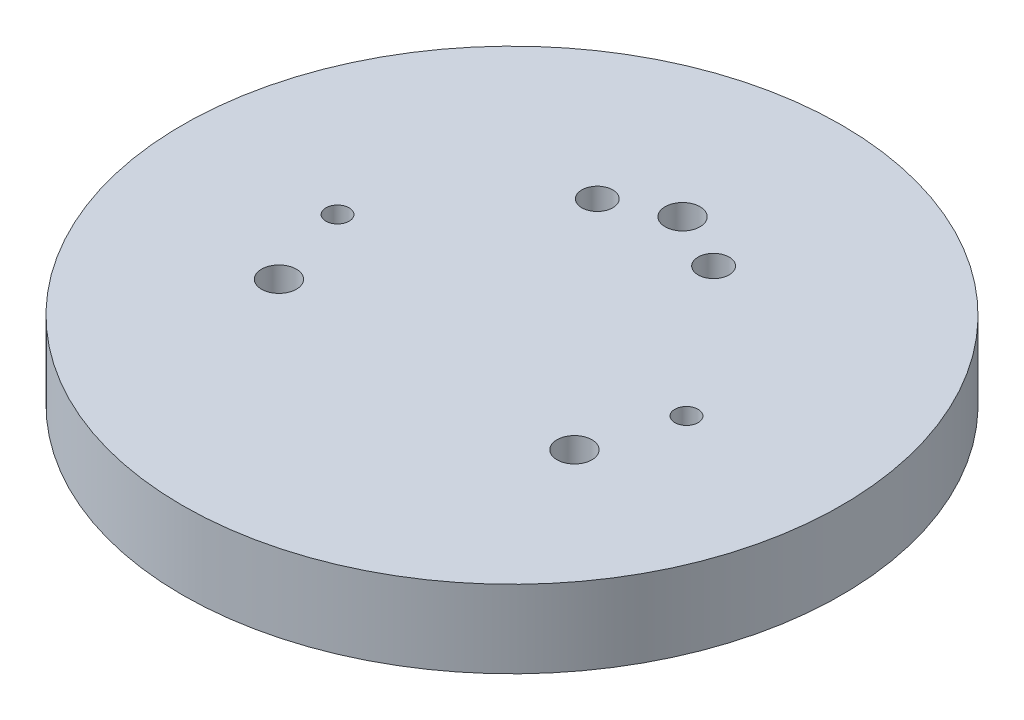
from build123d import *

# Parameters (mm, degrees)
SKETCH1_R           = 42.5
BOSS_EXTRUDE1_DEPTH = 10
SKETCH2_R           = 1.5
CUT_EXTRUDE1_DEPTH  = 5
SKETCH3_R           = 2.25
CUT_EXTRUDE2_DEPTH  = 11
SKETCH4_R           = 5
CUT_EXTRUDE3_DEPTH  = 4.4
SKETCH5_R           = 2
CUT_EXTRUDE4_DEPTH  = 11


with BuildPart() as part:
    # Sketch1 → Boss-Extrude1 (new body)
    with BuildSketch(Plane(origin=(0, 0, 0), x_dir=(1, 0, 0), z_dir=(0, 1, 0))):
        Circle(SKETCH1_R)
    extrude(amount=BOSS_EXTRUDE1_DEPTH)

    # Sketch2 → Cut-Extrude1 (cut)
    with BuildSketch(Plane(origin=(0, 10, 0), x_dir=(1, 0, 0), z_dir=(0, 1, 0))):
        with Locations((-22.5, 0)):
            Circle(SKETCH2_R)
        with Locations((22.5, 0)):
            Circle(SKETCH2_R)
    extrude(amount=-CUT_EXTRUDE1_DEPTH, mode=Mode.SUBTRACT)

    # Sketch3 → Cut-Extrude2 (cut, through all)
    with BuildSketch(Plane(origin=(0, 10, 0), x_dir=(1, 0, 0), z_dir=(0, 1, 0))):
        with Locations((0, 22)):
            Circle(SKETCH3_R)
        with Locations((19.052558883, -11)):
            Circle(SKETCH3_R)
        with Locations((-19.052558883, -11)):
            Circle(SKETCH3_R)
    extrude(amount=-CUT_EXTRUDE2_DEPTH, mode=Mode.SUBTRACT)

    # Sketch4 → Cut-Extrude3 (cut)
    with BuildSketch(Plane.XZ):
        with Locations((0, -22)):
            Circle(SKETCH4_R)
        with Locations((19.052558883, 11)):
            Circle(SKETCH4_R)
        with Locations((-19.052558883, 11)):
            Circle(SKETCH4_R)
    extrude(amount=-CUT_EXTRUDE3_DEPTH, mode=Mode.SUBTRACT)

    # Sketch5 → Cut-Extrude4 (cut, through all)
    with BuildSketch(Plane(origin=(0, 10, 0), x_dir=(1, 0, 0), z_dir=(0, 1, 0))):
        with Locations((-7.5, 18.5)):
            Circle(SKETCH5_R)
        with Locations((7.5, 18.5)):
            Circle(SKETCH5_R)
    extrude(amount=-CUT_EXTRUDE4_DEPTH, mode=Mode.SUBTRACT)


solid = part.part
